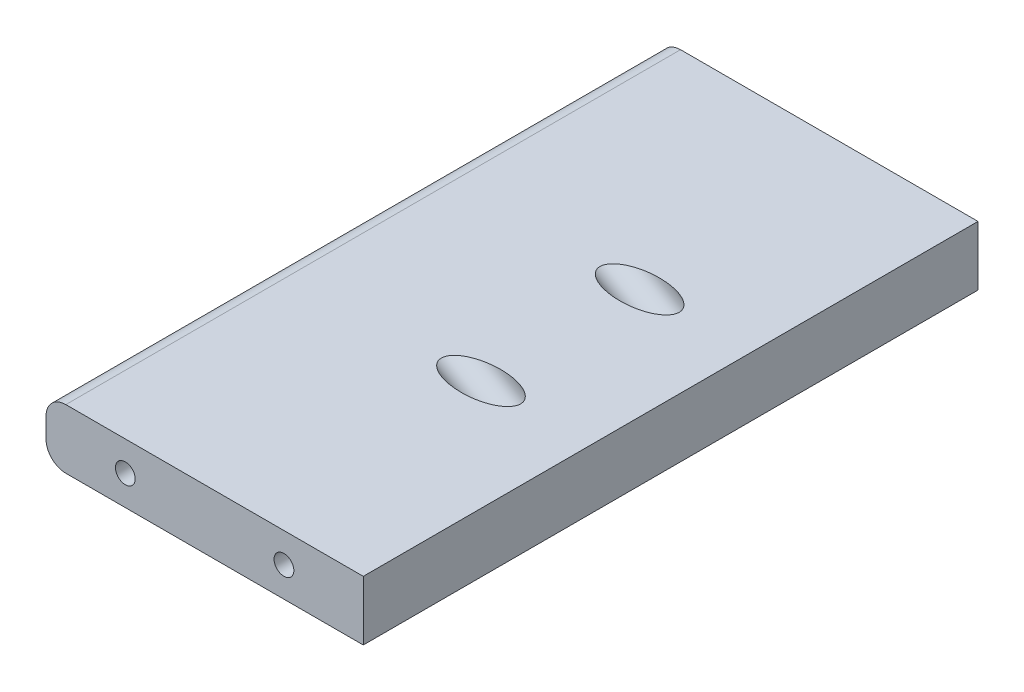
from build123d import *

# Parameters (mm, degrees)
BOSS_EXTRUDE1_DEPTH = 98.425
SKETCH2_R           = 3.175
CUT_EXTRUDE1_DEPTH  = 12.7
SKETCH3_R           = 6.35
CUT_EXTRUDE2_DEPTH  = 66.04


with BuildPart() as part:
    # Sketch1 → Boss-Extrude1 (new body, symmetric)
    with BuildSketch(Plane.XY):
        with BuildLine():
            Line((44.45, 9.525), (50.8, 9.525))
            Line((50.8, 9.525), (50.8, 3.175))
            Line((50.8, 3.175), (50.8, -3.175))
            Line((50.8, -3.175), (50.8, -9.525))
            Line((50.8, -9.525), (44.45, -9.525))
            Line((44.45, -9.525), (-44.45, -9.525))
            ThreePointArc((-44.45, -9.525), (-48.940128061, -7.665128061), (-50.8, -3.175))
            Line((-50.8, -3.175), (-50.8, 3.175))
            ThreePointArc((-50.8, 3.175), (-48.940128061, 7.665128061), (-44.45, 9.525))
            Line((-44.45, 9.525), (44.45, 9.525))
        make_face()
    extrude(amount=BOSS_EXTRUDE1_DEPTH, both=True)

    # Sketch2 → Cut-Extrude1 (cut)
    with BuildSketch(Plane.XY.offset(98.425)):
        with Locations((-25.4, 0)):
            Circle(SKETCH2_R)
        with Locations((25.4, 0)):
            Circle(SKETCH2_R)
    cut_extrude1 = extrude(amount=-CUT_EXTRUDE1_DEPTH, mode=Mode.SUBTRACT)

    # Sketch3 → Cut-Extrude2 (cut)
    with BuildSketch(Plane(origin=(-37.461945986, 21.628664599, 0), x_dir=(0, 0, -1), z_dir=(0.866025404, -0.5, 0))):
        with Locations(Location((-25.4, 15.982254693, 0), (0, 0, 270))):  # turned: the seam where the file's is
            Circle(SKETCH3_R)
        with Locations(Location((25.4, 15.982254693, 0), (0, 0, 270))):  # turned: the seam where the file's is
            Circle(SKETCH3_R)
    extrude(amount=CUT_EXTRUDE2_DEPTH, mode=Mode.SUBTRACT)

    # Mirror1: Cut-Extrude1 across plane
    add(cut_extrude1.mirror(Plane.XY), mode=Mode.SUBTRACT)


solid = part.part
